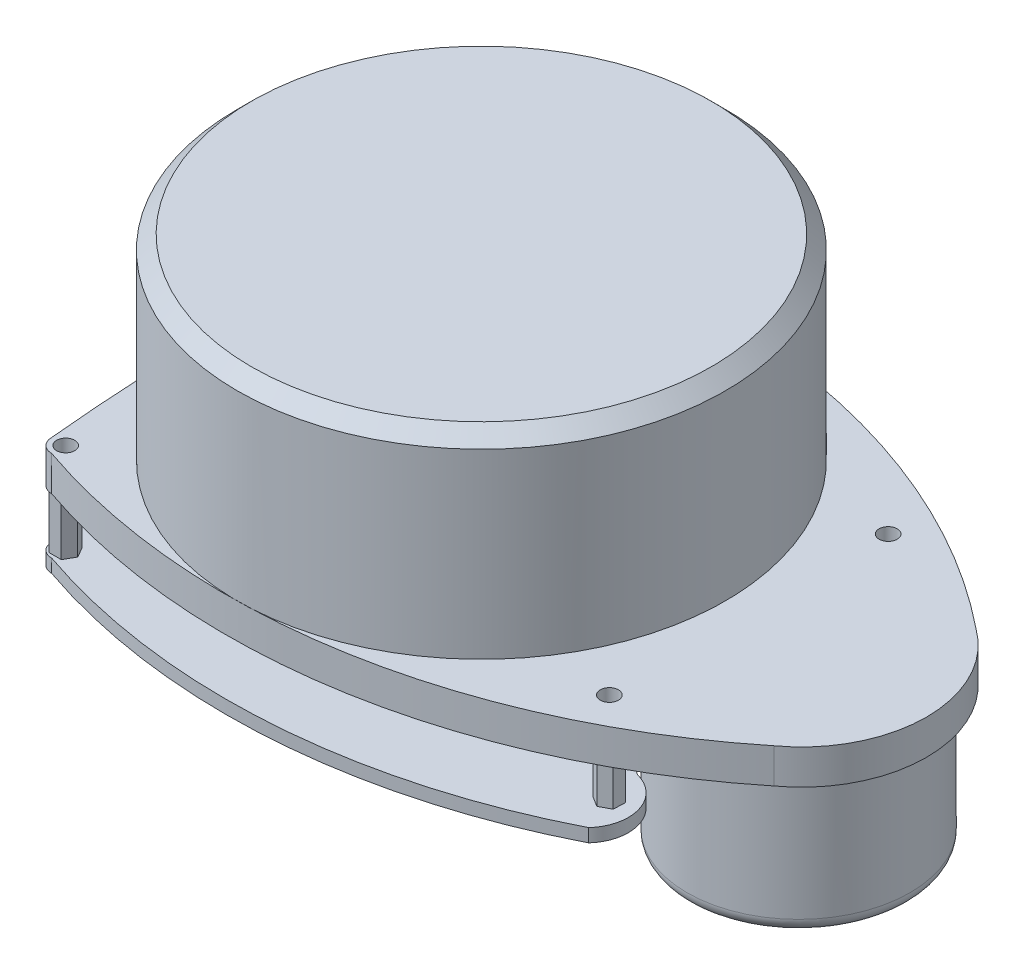
from build123d import *

# Parameters (mm, degrees)
SKETCH3_R           = 1.3
BOSS_EXTRUDE2_DEPTH = 5
SKETCH5_R           = 35
BOSS_EXTRUDE4_DEPTH = 28.1
CHAMFER2_SIZE       = 2
SKETCH6_R           = 25
BOSS_EXTRUDE5_DEPTH = 3
CHAMFER3_SIZE       = 1
SKETCH7_R           = 16
BOSS_EXTRUDE6_DEPTH = 20
SKETCH8_R           = 3.55
BOSS_EXTRUDE7_DEPTH = 2
FILLET1_R           = 2
SKETCH9_R           = 1.3
BOSS_EXTRUDE8_DEPTH = 8
SKETCH11_R          = 1.3
BOSS_EXTRUDE9_DEPTH = 1.9


with BuildPart() as part:
    # Sketch3 → Boss-Extrude2 (new body)
    with BuildSketch(Plane(origin=(0, 0, 0), x_dir=(1, 0, 0), z_dir=(0, 1, 0))):
        with BuildLine():
            ThreePointArc((-46.25, 30), (-47.664213562, 29.414213562), (-48.25, 28))
            ThreePointArc((-48.25, 28), (-49.607700542, 0), (-48.25, -28))
            ThreePointArc((-48.25, -28), (-47.664213562, -29.414213562), (-46.25, -30))
            ThreePointArc((-46.25, -30), (-0.19378614, -33.636910917), (41.856895399, -14.502069967))
            ThreePointArc((41.856895399, -14.502069967), (49.25, 0), (41.856895399, 14.502069967))
            ThreePointArc((41.856895399, 14.502069967), (-0.19378614, 33.636910917), (-46.25, 30))
        make_face()
        with Locations((-46.25, 28)):
            Circle(SKETCH3_R, mode=Mode.SUBTRACT)
        with Locations((-46.25, -28)):
            Circle(SKETCH3_R, mode=Mode.SUBTRACT)
        with Locations((23.75, 20)):
            Circle(SKETCH3_R, mode=Mode.SUBTRACT)
        with Locations((23.75, -20)):
            Circle(SKETCH3_R, mode=Mode.SUBTRACT)
    extrude(amount=BOSS_EXTRUDE2_DEPTH)

    # Sketch5 → Boss-Extrude4 (add)
    with BuildSketch(Plane(origin=(0, 5, 0), x_dir=(1, 0, 0), z_dir=(0, 1, 0))):
        with Locations((-14.607700542, 0)):
            Circle(SKETCH5_R)
    extrude(amount=BOSS_EXTRUDE4_DEPTH)

    # Chamfer2
    chamfer2_edges = [part.edges().sort_by_distance(p)[0] for p in [
        (-49.607700542, 33.1, 0),
    ]]
    chamfer(chamfer2_edges, length=CHAMFER2_SIZE)

    # Sketch6 → Boss-Extrude5 (add)
    with BuildSketch(Plane.XZ):
        with Locations((-14.607700542, 0)):
            Circle(SKETCH6_R)
    extrude(amount=BOSS_EXTRUDE5_DEPTH)

    # Chamfer3
    chamfer3_edges = [part.edges().sort_by_distance(p)[0] for p in [
        (-39.607700542, -3, 0),
    ]]
    chamfer(chamfer3_edges, length=CHAMFER3_SIZE)

    # Sketch7 → Boss-Extrude6 (add)
    with BuildSketch(Plane.XZ):
        with Locations((30.892299458, 0)):
            Circle(SKETCH7_R)
    extrude(amount=BOSS_EXTRUDE6_DEPTH)

    # Sketch8 → Boss-Extrude7 (add)
    with BuildSketch(Plane.XZ.offset(20)):
        with Locations((30.892299458, 0)):
            Circle(SKETCH8_R)
    extrude(amount=BOSS_EXTRUDE7_DEPTH)

    # Fillet1
    fillet1_edges = [part.edges().sort_by_distance(p)[0] for p in [
        (14.892299458, -20, 0),
    ]]
    fillet(fillet1_edges, radius=FILLET1_R)

    # Sketch9 → Boss-Extrude8 (add)
    with BuildSketch(Plane.XZ):
        Polygon((22.667730051, -18.647708701), (22.037746407, -20.261127619), (23.120016356, -21.613418919), (24.832269949, -21.352291299), (25.462253593, -19.738872381), (24.379983644, -18.386581081), align=None)
        with Locations((23.75, -20)):
            Circle(SKETCH9_R, mode=Mode.SUBTRACT)
        Polygon((-47.27859803, -26.606448389), (-47.971150112, -28.194016218), (-46.942552082, -29.58756783), (-45.22140197, -29.393551611), (-44.528849888, -27.805983782), (-45.557447918, -26.41243217), align=None)
        with Locations((-46.25, -28)):
            Circle(SKETCH9_R, mode=Mode.SUBTRACT)
        Polygon((-47.117302489, 29.499261949), (-47.98205018, 27.998524986), (-47.11474769, 26.499263037), (-45.382697511, 26.500738051), (-44.51794982, 28.001475014), (-45.38525231, 29.500736963), align=None)
        with Locations((-46.25, 28)):
            Circle(SKETCH9_R, mode=Mode.SUBTRACT)
        Polygon((22.220041565, 20.811928069), (22.281870449, 19.080981163), (23.811828884, 18.269053095), (25.279958435, 19.188071931), (25.218129551, 20.919018837), (23.688171116, 21.730946905), align=None)
        with Locations((23.75, 20)):
            Circle(SKETCH9_R, mode=Mode.SUBTRACT)
    extrude(amount=BOSS_EXTRUDE8_DEPTH)

    # Sketch11 → Boss-Extrude9 (add)
    with BuildSketch(Plane(origin=(0, -8, 0), x_dir=(-1, 0, 0), z_dir=(0, -1, 0))):
        with BuildLine():
            ThreePointArc((46.25, 30), (9.738587829, 34.807277641), (-25.746736736, 24.959187593))
            ThreePointArc((-25.746736736, 24.959187593), (-27.89999608, 19.965760464), (-24.474790494, 15.742159277))
            ThreePointArc((-24.474790494, 15.742159277), (-13.920811193, 0.984167698), (-22.698167109, -14.894837865))
            ThreePointArc((-22.698167109, -14.894837865), (-27.065884089, -19.065715062), (-25.746736736, -24.959187593))
            ThreePointArc((-25.746736736, -24.959187593), (9.738587829, -34.807277641), (46.25, -30))
            ThreePointArc((46.25, -30), (47.664213562, -29.414213562), (48.25, -28))
            ThreePointArc((48.25, -28), (49.607700542, 0), (48.25, 28))
            ThreePointArc((48.25, 28), (47.664213562, 29.414213562), (46.25, 30))
        make_face()
        with Locations((-23.75, 20)):
            Circle(SKETCH11_R, mode=Mode.SUBTRACT)
        with Locations((-23.75, -20)):
            Circle(SKETCH11_R, mode=Mode.SUBTRACT)
        with Locations((46.25, -28)):
            Circle(SKETCH11_R, mode=Mode.SUBTRACT)
        with Locations((46.25, 28)):
            Circle(SKETCH11_R, mode=Mode.SUBTRACT)
    extrude(amount=BOSS_EXTRUDE9_DEPTH)


solid = part.part
